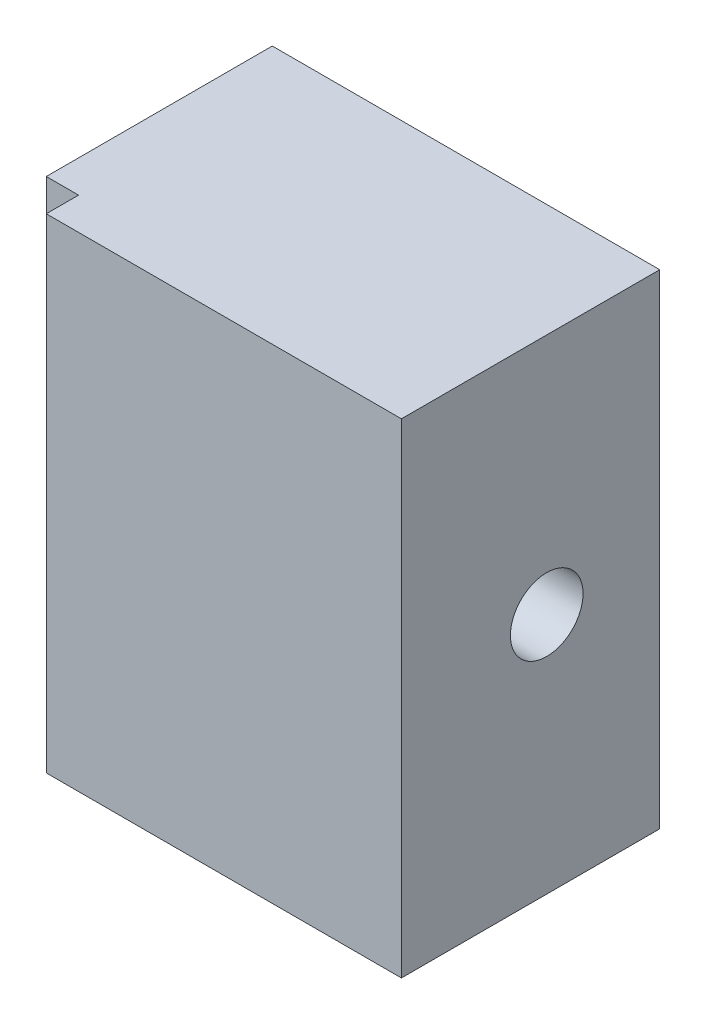
from build123d import *

# Parameters (mm, degrees)
SKETCH1_W            = 16
SKETCH1_H            = 30
BOSS_EXTRUDE1_DEPTH  = 24
SKETCH2_W            = 2
SKETCH2_H            = 30
CUT_EXTRUDE1_DEPTH   = 2
M4_CLEARANCE_HOLE1_D = 4.5


with BuildPart() as part:
    # Sketch1 → Boss-Extrude1 (new body)
    with BuildSketch(Plane(origin=(0, 0, 0), x_dir=(0, 0, -1), z_dir=(1, 0, 0))):
        with Locations((-8, 15)):
            Rectangle(SKETCH1_W, SKETCH1_H)
    extrude(amount=BOSS_EXTRUDE1_DEPTH)

    # Sketch2 → Cut-Extrude1 (cut)
    with BuildSketch(Plane.ZY):
        with Locations((15, 15)):
            Rectangle(SKETCH2_W, SKETCH2_H)
    extrude(amount=-CUT_EXTRUDE1_DEPTH, mode=Mode.SUBTRACT)

    # M4 Clearance Hole1 (through all)
    with Locations(Plane(origin=(24, 0, 0), x_dir=(0, 0, -1), z_dir=(1, 0, 0))):
        with Locations((-7, 15)):
            Hole(M4_CLEARANCE_HOLE1_D / 2)


solid = part.part
